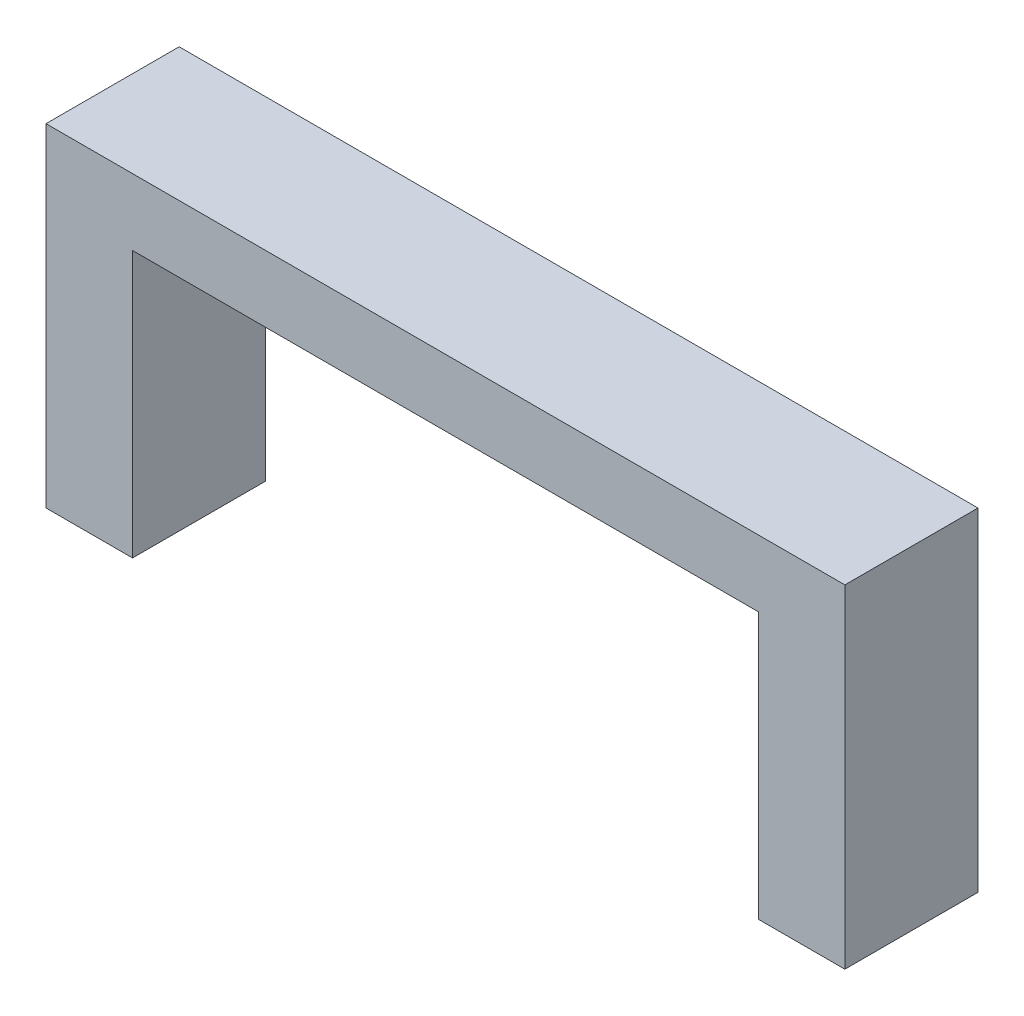
from build123d import *

# Parameters (mm, degrees)
BOSS_EXTRUDE1_DEPTH = 10


with BuildPart() as part:
    # Sketch1 → Boss-Extrude1 (new body)
    with BuildSketch(Plane.XY):
        Polygon((-30, 5), (30, 5), (30, -20), (23.5, -20), (23.5, 0), (-23.5, 0), (-23.5, -20), (-30, -20), align=None)
    extrude(amount=BOSS_EXTRUDE1_DEPTH)


solid = part.part
